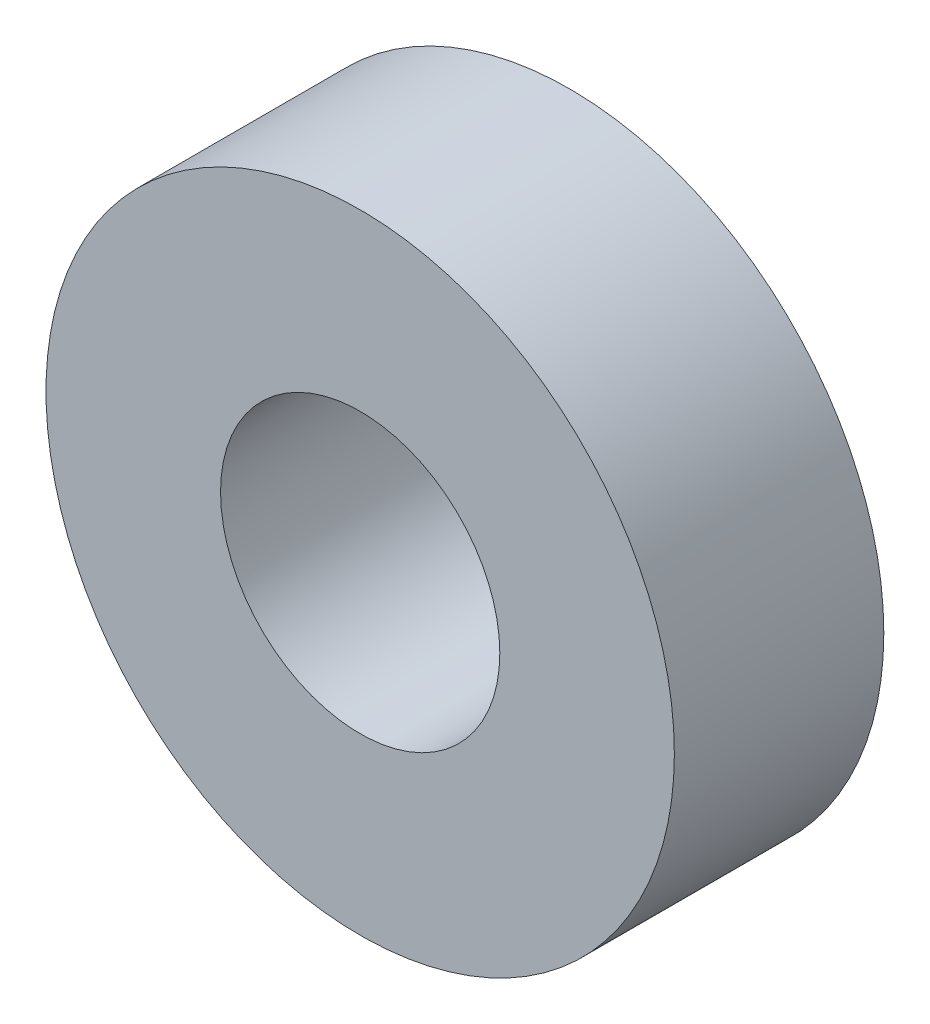
from build123d import *

# Parameters (mm, degrees)
BOSS_EXTRUDE1_DEPTH      = 3
BOSS_EXTRUDE1_DEPTH_BACK = 3
SKETCH1_R                = 9
SKETCH1_R_2              = 4


with BuildPart() as part:
    # Sketch1 → Boss-Extrude1 (new, two sides: drawn at the far end of the back side and taken through both)
    with BuildSketch(Plane.XY.offset(-BOSS_EXTRUDE1_DEPTH_BACK)):
        Circle(SKETCH1_R)
        Circle(SKETCH1_R_2, mode=Mode.SUBTRACT)
    extrude(amount=BOSS_EXTRUDE1_DEPTH + BOSS_EXTRUDE1_DEPTH_BACK)


solid = part.part
